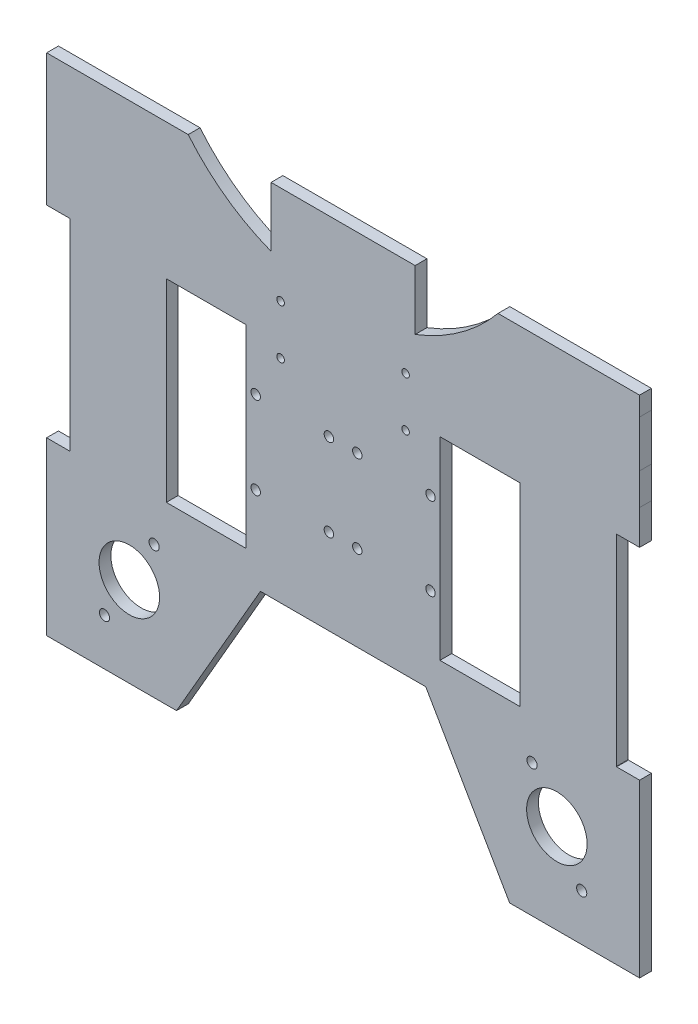
from build123d import *

# Parameters (mm, degrees)
SKETCH1_R           = 2.153330351
SKETCH1_R_2         = 12.817442563
SKETCH1_W           = 33.838048367
SKETCH1_H           = 82.031632405
BOSS_EXTRUDE1_DEPTH = 5
SKETCH5_R           = 62
CUT_EXTRUDE3_DEPTH  = 5
SKETCH6_R           = 1.6
SKETCH6_R_2         = 2
CUT_EXTRUDE4_DEPTH  = 10
BOSS_EXTRUDE2_DEPTH = 5
CUT_EXTRUDE5_DEPTH  = 30


with BuildPart() as part:
    # Sketch1 → Boss-Extrude1 (new body)
    with BuildSketch(Plane.XY):
        with BuildLine():
            Line((125.53231807, 103.262634184), (91.381905468, 103.262634184))
            Line((91.381905468, 103.262634184), (77.913526918, 103.262634184))
            Line((77.913526918, 103.262634184), (36.253297751, 103.262634184))
            ThreePointArc((36.253297751, 103.262634184), (0, 93.454499378), (-36.253297751, 103.262634184))
            Line((-36.253297751, 103.262634184), (-77.913526918, 103.262634184))
            Line((-77.913526918, 103.262634184), (-91.381905468, 103.262634184))
            Line((-91.381905468, 103.262634184), (-125.53231807, 103.262634184))
            Line((-125.53231807, 103.262634184), (-125.54905558, 83.520799446))
            Line((-125.54905558, 83.520799446), (-125.554160174, 70.087177042))
            Line((-125.554160174, 70.087177042), (-125.554470078, 55.465919402))
            Line((-125.554470078, 55.465919402), (-115.83891891, 55.465919402))
            Line((-115.83891891, 55.465919402), (-115.711941884, 55.465919402))
            Line((-115.711941884, 55.465919402), (-115.711941884, 55.338942376))
            Line((-115.711941884, 55.338942376), (-115.711941884, -29.754151955))
            Line((-115.711941884, -29.754151955), (-115.711941884, -29.88112898))
            Line((-115.711941884, -29.88112898), (-115.83891891, -29.88112898))
            Line((-115.83891891, -29.88112898), (-125.555737773, -29.88112898))
            Line((-125.555737773, -29.88112898), (-125.555737773, -59.42445768))
            Line((-125.555737773, -59.42445768), (-125.555737773, -72.892836229))
            Line((-125.555737773, -72.892836229), (-125.555737773, -102.437610833))
            Line((-125.555737773, -102.437610833), (-101.198740966, -102.437610833))
            Line((-101.198740966, -102.437610833), (-87.730362416, -102.437610833))
            Line((-87.730362416, -102.437610833), (-70.522775483, -102.437610833))
            Line((-70.522775483, -102.437610833), (-52.513332124, -71.244339919))
            Line((-52.513332124, -71.244339919), (-47.927289793, -63.301081597))
            Line((-47.927289793, -63.301081597), (-35.002036695, -40.91388653))
            Line((-35.002036695, -40.91388653), (-5.325262411, -40.91388653))
            Line((-5.325262411, -40.91388653), (5.324834587, -40.91388653))
            Line((5.324834587, -40.91388653), (35.002036695, -40.91388653))
            Line((35.002036695, -40.91388653), (47.927289793, -63.301081597))
            Line((47.927289793, -63.301081597), (52.513332124, -71.244339919))
            Line((52.513332124, -71.244339919), (70.522775483, -102.437610833))
            Line((70.522775483, -102.437610833), (87.730362416, -102.437610833))
            Line((87.730362416, -102.437610833), (101.198740966, -102.437610833))
            Line((101.198740966, -102.437610833), (125.555737773, -102.437610833))
            Line((125.555737773, -102.437610833), (125.555737773, -72.892113277))
            Line((125.555737773, -72.892113277), (125.555737773, -59.423734727))
            Line((125.555737773, -59.423734727), (125.555737773, -29.88112898))
            Line((125.555737773, -29.88112898), (115.83891891, -29.88112898))
            ThreePointArc((115.83891891, -29.88112898), (115.749132594, -29.843938271), (115.711941884, -29.754151955))
            Line((115.711941884, -29.754151955), (115.711941884, 55.338942376))
            ThreePointArc((115.711941884, 55.338942376), (115.749132594, 55.428728692), (115.83891891, 55.465919402))
            Line((115.83891891, 55.465919402), (125.554470078, 55.465919402))
            Line((125.554470078, 55.465919402), (125.554160387, 70.077114789))
            Line((125.554160387, 70.077114789), (125.549047054, 83.530856147))
            Line((125.549047054, 83.530856147), (125.53231807, 103.262634184))
        make_face()
        with Locations((-101.032414216, -82.661089892)):
            Circle(SKETCH1_R, mode=Mode.SUBTRACT)
        with Locations((-90.522111314, -64.456711263)):
            Circle(SKETCH1_R_2, mode=Mode.SUBTRACT)
        with Locations((-80.011808412, -46.252332635)):
            Circle(SKETCH1_R, mode=Mode.SUBTRACT)
        with Locations((80.011808412, -46.252332635)):
            Circle(SKETCH1_R, mode=Mode.SUBTRACT)
        with Locations((90.522111314, -64.456711263)):
            Circle(SKETCH1_R_2, mode=Mode.SUBTRACT)
        with Locations((101.032414216, -82.661089892)):
            Circle(SKETCH1_R, mode=Mode.SUBTRACT)
        with Locations((57.934840386, 12.792395211)):
            Rectangle(SKETCH1_W, SKETCH1_H, mode=Mode.SUBTRACT)
        with Locations((-57.934840386, 12.792395211)):
            Rectangle(SKETCH1_W, SKETCH1_H, mode=Mode.SUBTRACT)
    extrude(amount=BOSS_EXTRUDE1_DEPTH)

    # Sketch5 → Cut-Extrude3 (cut)
    with BuildSketch(Plane.XY.offset(5)):
        with Locations((0, 135.292395211)):
            Circle(SKETCH5_R)
    extrude(amount=-CUT_EXTRUDE3_DEPTH, mode=Mode.SUBTRACT)

    # Sketch6 → Cut-Extrude4 (cut)
    with BuildSketch(Plane.XY.offset(5)):
        with Locations((26.464466094, 69.756861305)):
            Circle(SKETCH6_R)
        with Locations((26.464466094, 48.827929116)):
            Circle(SKETCH6_R)
        with Locations((-26.464466094, 69.756861305)):
            Circle(SKETCH6_R)
        with Locations((-26.464466094, 48.827929116)):
            Circle(SKETCH6_R)
        with Locations((-37.015816202, 30.292395211)):
            Circle(SKETCH6_R_2)
        with Locations((-37.015816202, -4.707604789)):
            Circle(SKETCH6_R_2)
        with Locations((-6.015816202, -4.707604789)):
            Circle(SKETCH6_R_2)
        with Locations((-6.015816202, 30.292395211)):
            Circle(SKETCH6_R_2)
        with Locations((6.015816202, 30.292395211)):
            Circle(SKETCH6_R_2)
        with Locations((6.015816202, -4.707604789)):
            Circle(SKETCH6_R_2)
        with Locations((37.015816202, 30.292395211)):
            Circle(SKETCH6_R_2)
        with Locations((37.015816202, -4.707604789)):
            Circle(SKETCH6_R_2)
    extrude(amount=-CUT_EXTRUDE4_DEPTH, mode=Mode.SUBTRACT)

    # Sketch8 → Boss-Extrude2 (add)
    with BuildSketch(Plane(origin=(0, 0, 0), x_dir=(-1, 0, 0), z_dir=(0, 0, -1))):
        with BuildLine():
            Line((-125.53231807, 103.262634184), (-125.53231807, 111.292395211))
            Line((-125.53231807, 111.292395211), (125.53231807, 111.292395211))
            Line((125.53231807, 111.292395211), (125.53231807, 103.262634184))
            Line((125.53231807, 103.262634184), (53.085726976, 103.262634184))
            ThreePointArc((53.085726976, 103.262634184), (0, 73.292395211), (-53.085726976, 103.262634184))
            Line((-53.085726976, 103.262634184), (-125.53231807, 103.262634184))
        make_face()
    extrude(amount=-BOSS_EXTRUDE2_DEPTH)

    # Sketch10 → Cut-Extrude5 (cut)
    with BuildSketch(Plane.XY.offset(5)):
        with BuildLine():
            Line((-30.5, 111.292395211), (-65.587998232, 111.292395211))
            ThreePointArc((-65.587998232, 111.292395211), (-51.367987693, 97.636707664), (-34.384510932, 87.624314384))
            ThreePointArc((-34.384510932, 87.624314384), (-32.452174676, 86.797991587), (-30.5, 86.01969421))
            Line((-30.5, 86.01969421), (-30.5, 111.292395211))
        make_face()
        with BuildLine():
            Line((65.587998232, 111.292395211), (30.5, 111.292395211))
            Line((30.5, 111.292395211), (30.5, 86.01969421))
            ThreePointArc((30.5, 86.01969421), (33.278602522, 87.144484688), (36.015816202, 88.366551325))
            ThreePointArc((36.015816202, 88.366551325), (52.079097115, 98.182018442), (65.587998232, 111.292395211))
        make_face()
    extrude(amount=-CUT_EXTRUDE5_DEPTH, mode=Mode.SUBTRACT)


solid = part.part
